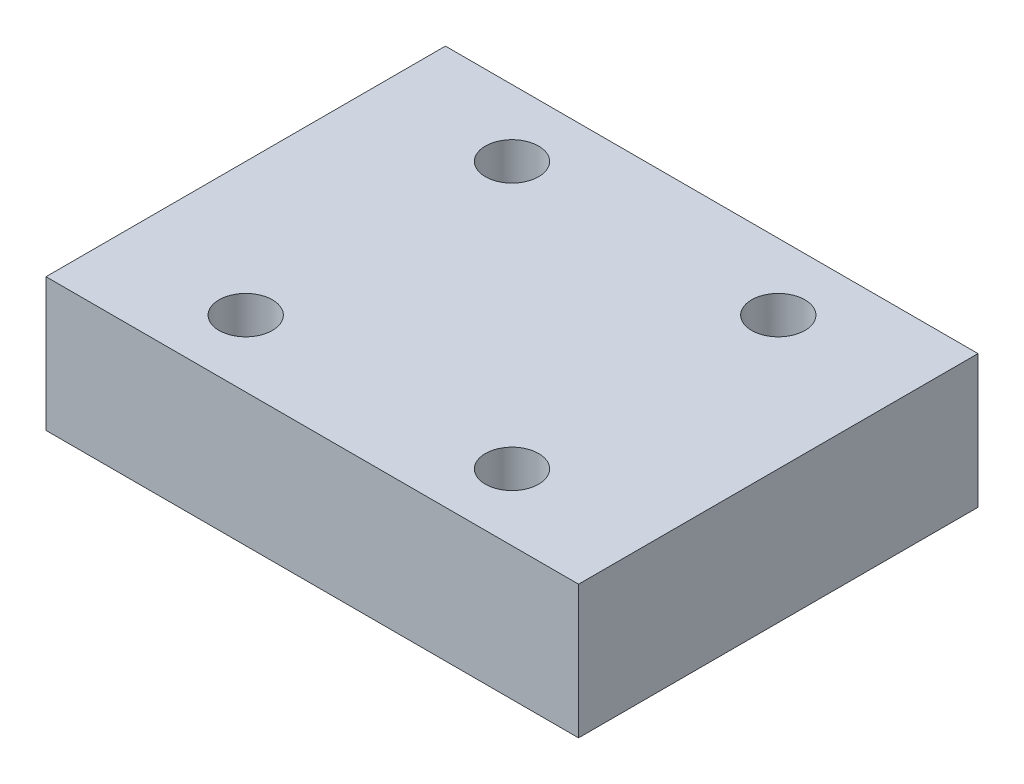
from build123d import *

# Parameters (mm, degrees)
SKETCH1_W           = 40
SKETCH1_H           = 30
BOSS_EXTRUDE1_DEPTH = 10
SKETCH2_R           = 2
CUT_EXTRUDE1_DEPTH  = 16


with BuildPart() as part:
    # Sketch1 → Boss-Extrude1 (new body)
    with BuildSketch(Plane(origin=(0, 0, 0), x_dir=(1, 0, 0), z_dir=(0, 1, 0))):
        Rectangle(SKETCH1_W, SKETCH1_H)
    extrude(amount=BOSS_EXTRUDE1_DEPTH)

    # Sketch2 → Cut-Extrude1 (cut)
    with BuildSketch(Plane(origin=(0, 10, 0), x_dir=(1, 0, 0), z_dir=(0, 1, 0))):
        with Locations((-10, 10)):
            Circle(SKETCH2_R)
        with Locations((10, 10)):
            Circle(SKETCH2_R)
        with Locations((10, -10)):
            Circle(SKETCH2_R)
        with Locations((-10, -10)):
            Circle(SKETCH2_R)
    extrude(amount=-CUT_EXTRUDE1_DEPTH, mode=Mode.SUBTRACT)


solid = part.part
